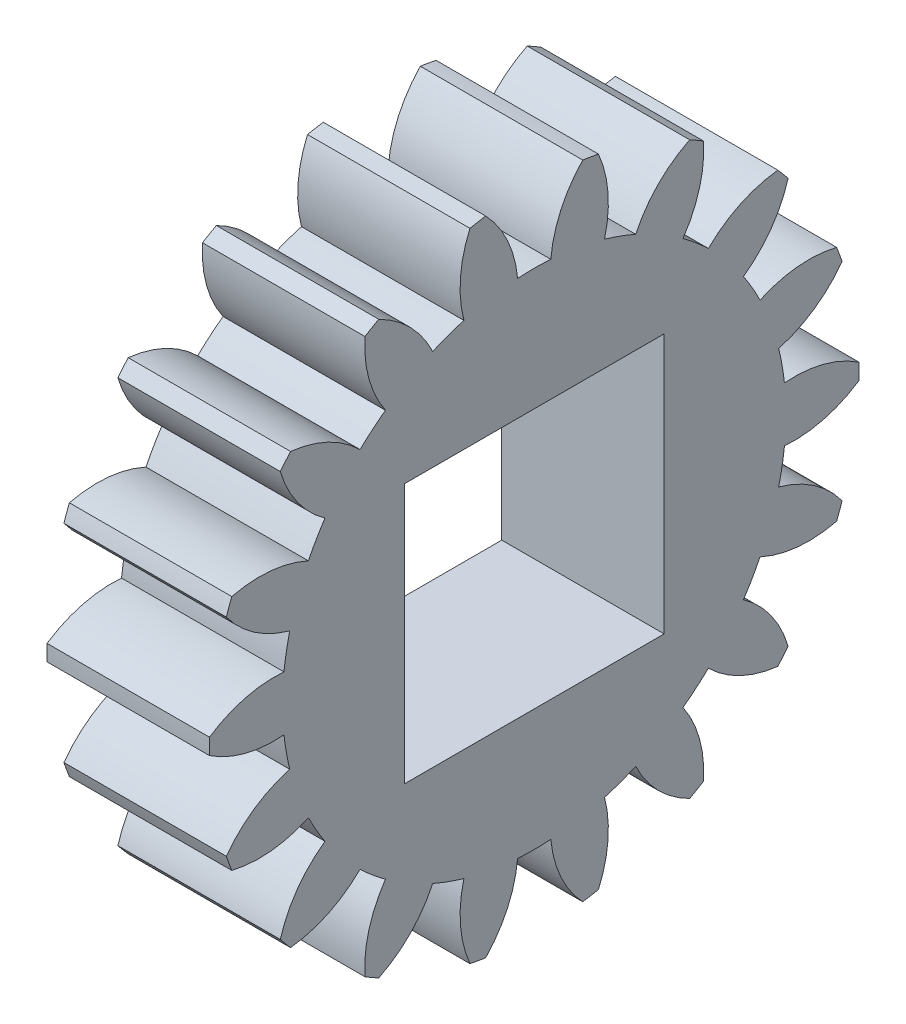
from build123d import *

# Parameters (mm, degrees)
BASPROSKE_W        = 5
BASPROSKE_H        = 10
TOOTHCUT_DEPTH     = 16
TEETHCUTS_COUNT    = 18
TEETHCUTS_ANGLE    = 340
BORSKE_R           = 2.5
BORE_DEPTH         = 50.0000508
SKETCH1_W          = 8
SKETCH1_H          = 8
CUT_EXTRUDE1_DEPTH = 15.925454152


with BuildPart() as part:
    # BasProSke → Base-Revolve (revolve)
    with BuildSketch(Plane(origin=(0, 0, 0), x_dir=(1, 0, 0), z_dir=(0, 1, 0)), mode=Mode.PRIVATE) as base_revolve_sk:
        with Locations((2.5, 5)):
            Rectangle(BASPROSKE_W, BASPROSKE_H)
    revolve(base_revolve_sk.sketch.rotate(Axis((-10, 0, 0), (1, 0, 0)), 180), axis=Axis((-10, 0, 0), (1, 0, 0)))

    # TooCutSke → ToothCut (cut, through all)
    with BuildSketch(Plane(origin=(0, 0, 0), x_dir=(0, 0, -1), z_dir=(1, 0, 0))):
        with BuildLine():
            ThreePointArc((0.510641536, 7.732156635), (0, 7.749), (-0.510641536, 7.732156635))
            ThreePointArc((-0.510641536, 7.732156635), (-0.82619259, 8.907320741), (-1.515208602, 9.910236529))
            ThreePointArc((-1.515208602, 9.910236529), (0, 10.0254), (1.515208602, 9.910236529))
            ThreePointArc((1.515208602, 9.910236529), (0.82619259, 8.907320741), (0.510641536, 7.732156635))
        make_face()
    toothcut = extrude(amount=TOOTHCUT_DEPTH, mode=Mode.SUBTRACT)

    # TeethCuts: ToothCut ×18 about axis
    teethcuts_axis = Axis((-10, 0, 0), (1, 0, 0))
    for i in range(1, TEETHCUTS_COUNT):
        add(toothcut.rotate(teethcuts_axis, i * TEETHCUTS_ANGLE / (TEETHCUTS_COUNT - 1)), mode=Mode.SUBTRACT)

    # BorSke → Bore (cut, symmetric)
    with BuildSketch(Plane(origin=(0, 0, 0), x_dir=(0, 0, -1), z_dir=(1, 0, 0))):
        with Locations(Location((0, 0, 0), (0, 0, 180))):
            Circle(BORSKE_R)
    extrude(amount=BORE_DEPTH, both=True, mode=Mode.SUBTRACT)

    # Sketch1 → Cut-Extrude1 (cut, through all)
    with BuildSketch(Plane(origin=(5, 0, 0), x_dir=(0, 0, -1), z_dir=(1, 0, 0))):
        Rectangle(SKETCH1_W, SKETCH1_H)
    extrude(amount=-CUT_EXTRUDE1_DEPTH, mode=Mode.SUBTRACT)


solid = part.part
